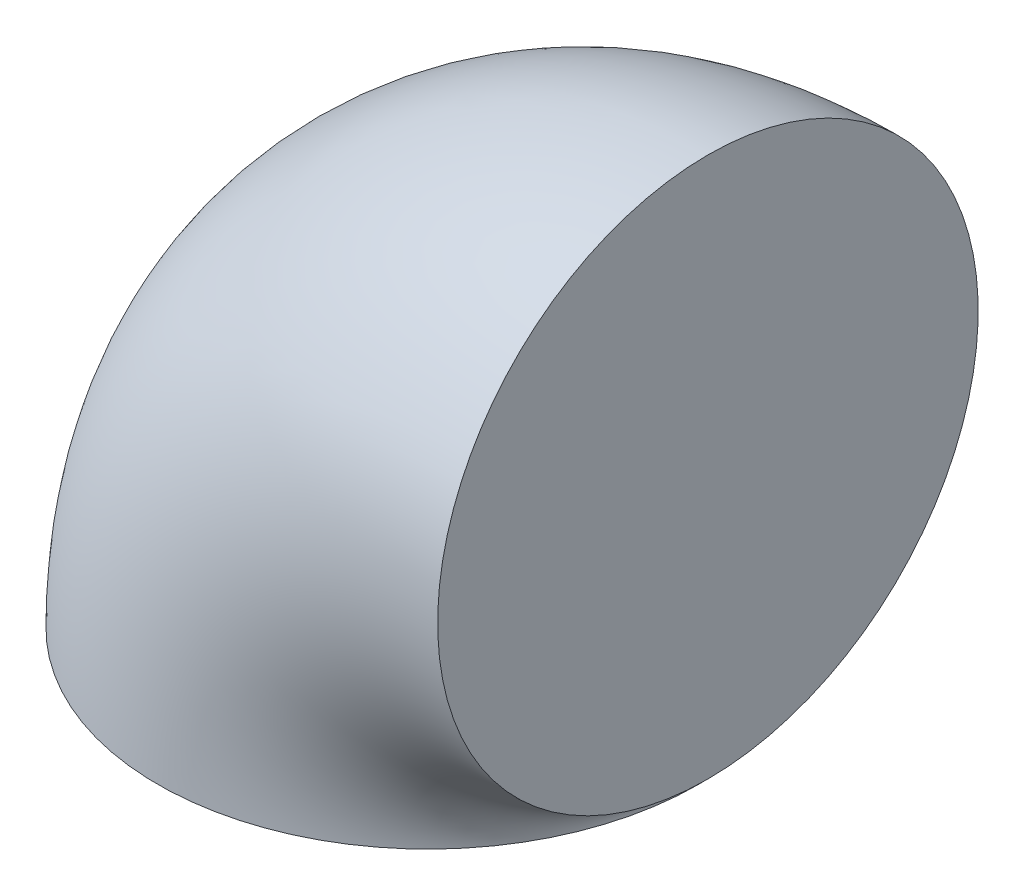
from build123d import *

# Parameters (mm, degrees)
ESBO_O1_R       = 62.5
REVOLU_O1_ANGLE = 90


with BuildPart() as part:
    # Esboço1 → Revolução1 (revolve)
    with BuildSketch(Plane(origin=(0, 0, 0), x_dir=(1, 0, 0), z_dir=(0, 1, 0))):
        Circle(ESBO_O1_R)
    revolve(axis=Axis((64.7, 0, 0), (0, 0, -1)), revolution_arc=REVOLU_O1_ANGLE)


solid = part.part
